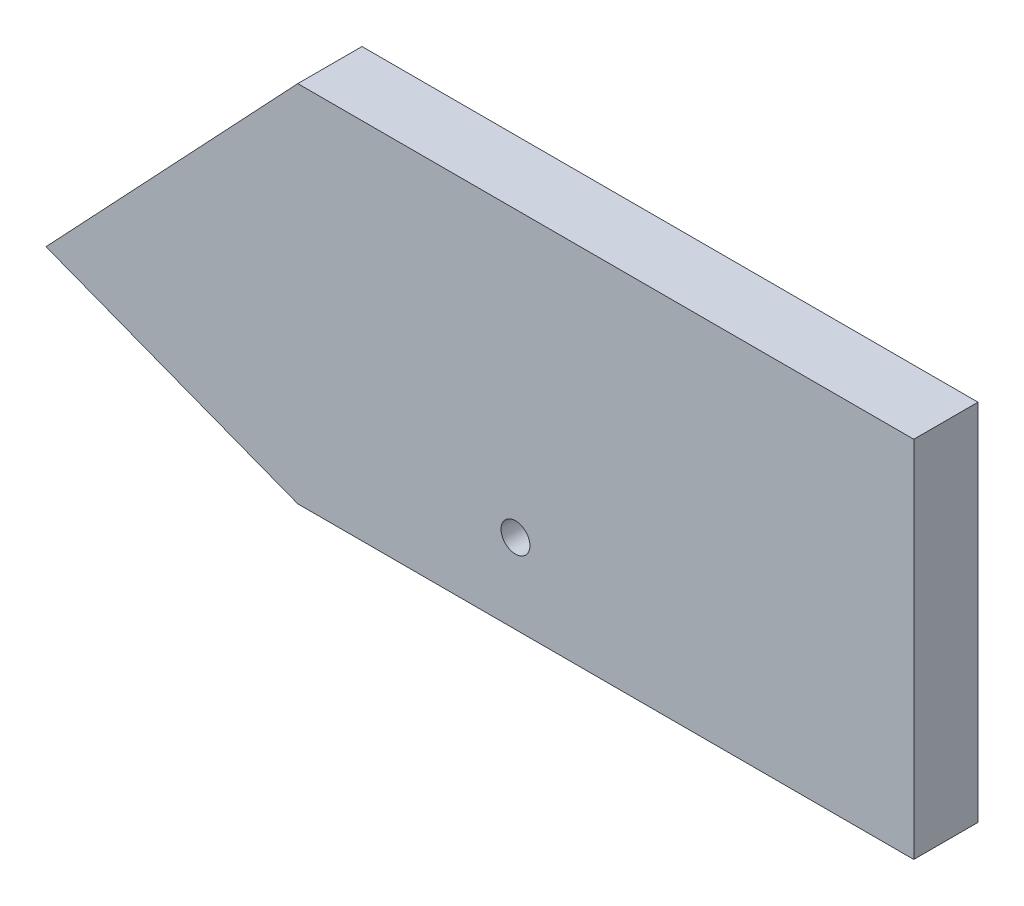
from build123d import *

# Parameters (mm, degrees)
BOSS_EXTRU_1_DEPTH = 10
D_GAGEMENT_M41_D   = 4.5


with BuildPart() as part:
    # ref externes (internes) → Boss.-Extru.1 (new body)
    with BuildSketch(Plane.XY):
        Polygon((-460.979412649, -138.268279633), (-556.886836405, -138.268279633), (-596.082218437, -179.852321051), (-556.886836405, -194.929034048), (-460.979412649, -194.929034048), align=None)
    extrude(amount=BOSS_EXTRU_1_DEPTH)

    # Dégagement M41 (through all)
    with Locations(Plane.XY.offset(10)):
        with Locations((-522.988022529, -182.510884742)):
            Hole(D_GAGEMENT_M41_D / 2)


solid = part.part
